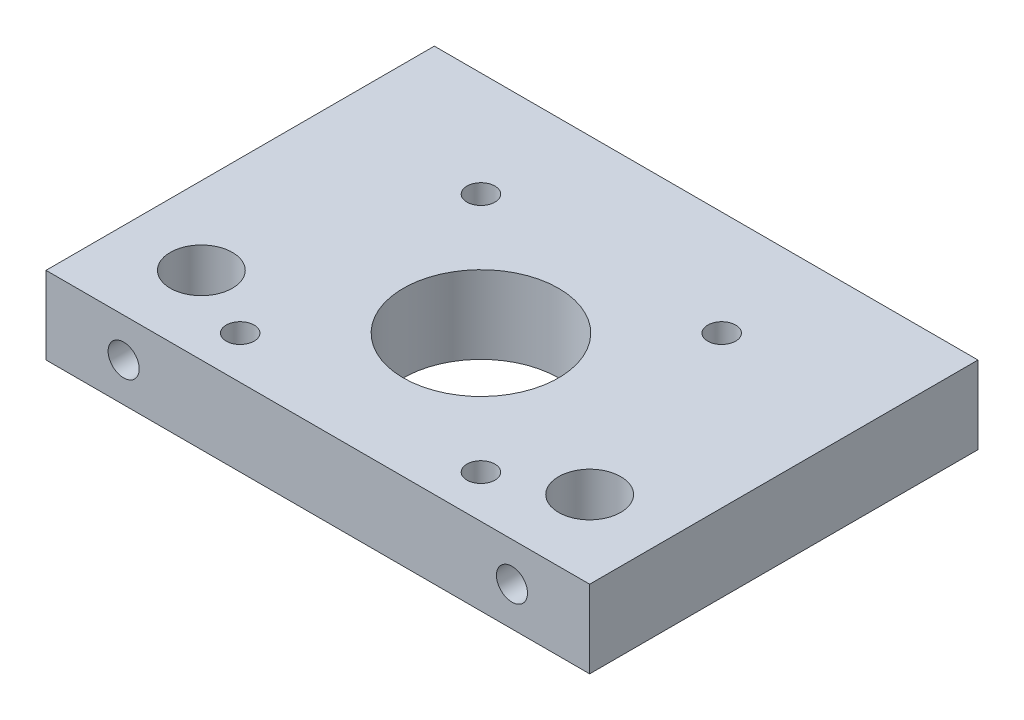
from build123d import *

# Parameters (mm, degrees)
SKETCH2_W           = 70
SKETCH2_H           = 50
BOSS_EXTRUDE1_DEPTH = 10
SKETCH3_R           = 4
CUT_EXTRUDE1_DEPTH  = 11
SKETCH4_R           = 1.8
CUT_EXTRUDE2_DEPTH  = 11
SKETCH5_R           = 10
CUT_EXTRUDE3_DEPTH  = 11
SKETCH6_R           = 2
CUT_EXTRUDE5_DEPTH  = 10


with BuildPart() as part:
    # Sketch2 → Boss-Extrude1 (new body)
    with BuildSketch(Plane(origin=(0, 0, 0), x_dir=(1, 0, 0), z_dir=(0, 1, 0))):
        Rectangle(SKETCH2_W, SKETCH2_H)
    extrude(amount=BOSS_EXTRUDE1_DEPTH)

    # Sketch3 → Cut-Extrude1 (cut, through all)
    with BuildSketch(Plane(origin=(0, 10, 0), x_dir=(1, 0, 0), z_dir=(0, 1, 0))):
        with Locations((-25, -15)):
            Circle(SKETCH3_R)
        with Locations((25, -15)):
            Circle(SKETCH3_R)
    extrude(amount=-CUT_EXTRUDE1_DEPTH, mode=Mode.SUBTRACT)

    # Sketch4 → Cut-Extrude2 (cut, through all)
    with BuildSketch(Plane.XZ):
        with Locations((-15.5, 19.5)):
            Circle(SKETCH4_R)
        with Locations((-15.5, -11.5)):
            Circle(SKETCH4_R)
        with Locations((15.5, -11.5)):
            Circle(SKETCH4_R)
        with Locations((15.5, 19.5)):
            Circle(SKETCH4_R)
    extrude(amount=-CUT_EXTRUDE2_DEPTH, mode=Mode.SUBTRACT)

    # Sketch5 → Cut-Extrude3 (cut, through all)
    with BuildSketch(Plane.XZ):
        with Locations((0, 4)):
            Circle(SKETCH5_R)
    extrude(amount=-CUT_EXTRUDE3_DEPTH, mode=Mode.SUBTRACT)

    # Sketch6 → Cut-Extrude5 (cut)
    with BuildSketch(Plane.XY.offset(25)):
        with Locations((25, 5)):
            Circle(SKETCH6_R)
        with Locations((-25, 5)):
            Circle(SKETCH6_R)
    extrude(amount=-CUT_EXTRUDE5_DEPTH, mode=Mode.SUBTRACT)


solid = part.part
